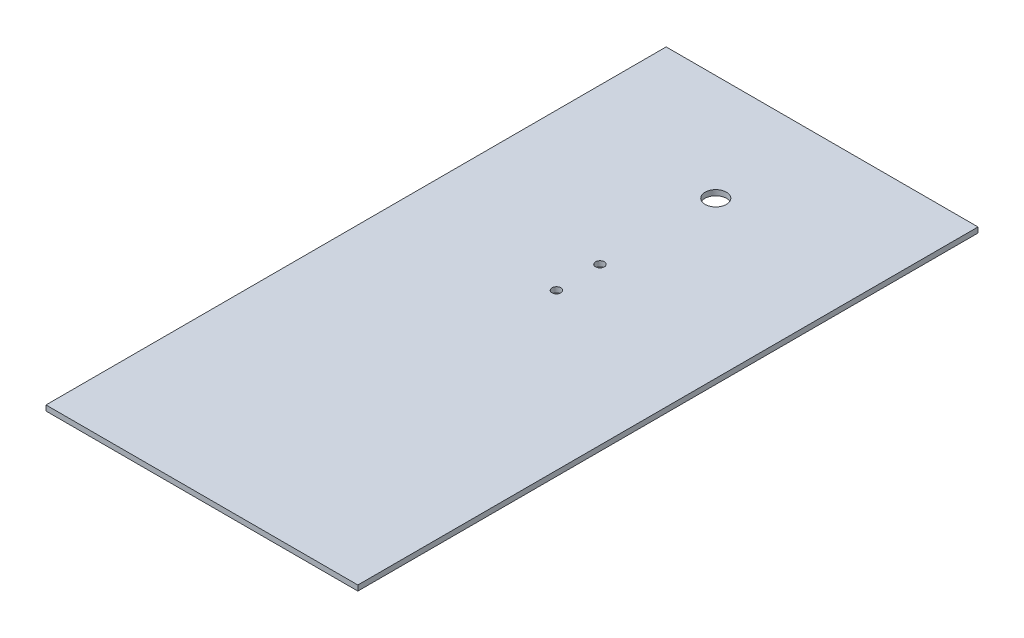
from build123d import *

# Parameters (mm, degrees)
SKETCH1_W                  = 176
SKETCH1_H                  = 350
BOSS_EXTRUDE1_DEPTH        = 3
F_5_0MM_DOWEL_HOLE1_D      = 5
F_5_0MM_DOWEL_HOLE1_DEPTH  = 3
F_12_0MM_DOWEL_HOLE1_D     = 12
F_12_0MM_DOWEL_HOLE1_DEPTH = 3
CUT_EXTRUDE3_DEPTH         = 0.5


with BuildPart() as part:
    # Sketch1 → Boss-Extrude1 (new body)
    with BuildSketch(Plane(origin=(0, 0, 0), x_dir=(1, 0, 0), z_dir=(0, 1, 0))):
        with Locations((88, 175)):
            Rectangle(SKETCH1_W, SKETCH1_H)
    extrude(amount=BOSS_EXTRUDE1_DEPTH)

    # Ø5.0mm Dowel Hole1
    with Locations(Plane(origin=(0, 0, 0), x_dir=(-1, 0, 0), z_dir=(0, -1, 0))):
        with Locations((-88.016913139, 200.06), (-87.591567674, 225.06)):
            Hole(F_5_0MM_DOWEL_HOLE1_D / 2, depth=F_5_0MM_DOWEL_HOLE1_DEPTH)

    # Ø12.0mm Dowel Hole1
    with Locations(Plane(origin=(0, 0, 0), x_dir=(-1, 0, 0), z_dir=(0, -1, 0))):
        with Locations((-88, 290)):
            Hole(F_12_0MM_DOWEL_HOLE1_D / 2, depth=F_12_0MM_DOWEL_HOLE1_DEPTH)

    # Sketch12 → Cut-Extrude3 (cut)
    with BuildSketch(Plane.XZ):
        with BuildLine():
            add(Edge.make_bspline(
                [(77.92675625, -206.794097), (77.93939, -206.794097), (78.28449275, -207.1306105), (78.693651, -207.54190525)],
                knots=[0, 0, 0, 0, 1, 1, 1, 1], degree=3))
            Line((78.693651, -207.54190525), (79.43757325, -208.2897145))
            Line((79.43757325, -208.2897145), (79.176767, -208.56564825))
            add(Edge.make_bspline(
                [(79.176767, -208.56564825), (79.03332975, -208.71741125), (78.538936, -209.15859025), (78.07812425, -209.546044)],
                knots=[0, 0, 0, 0, 1, 1, 1, 1], degree=3))
            add(Edge.make_bspline(
                [(78.07812425, -209.546044), (74.3622895, -212.67031475), (69.4527275, -214.46641025), (64.62846725, -214.46641025)],
                knots=[0, 0, 0, 0, 1, 1, 1, 1], degree=3))
            add(Edge.make_bspline(
                [(64.62846725, -214.46641025), (59.80542375, -214.46641025), (54.906584, -212.67482525), (51.1788165, -209.5476475)],
                knots=[0, 0, 0, 0, 1, 1, 1, 1], degree=3))
            add(Edge.make_bspline(
                [(51.1788165, -209.5476475), (50.7179985, -209.16107525), (50.26398675, -208.75889), (50.16990075, -208.653904)],
                knots=[0, 0, 0, 0, 1, 1, 1, 1], degree=3))
            Line((50.16990075, -208.653904), (49.99882125, -208.46301975))
            Line((49.99882125, -208.46301975), (50.7412155, -207.7167525))
            add(Edge.make_bspline(
                [(50.7412155, -207.7167525), (51.14952725, -207.30630575), (51.50432675, -206.971895), (51.5296475, -206.97361675)],
                knots=[0, 0, 0, 0, 1, 1, 1, 1], degree=3))
            add(Edge.make_bspline(
                [(51.5296475, -206.97361675), (51.55497475, -206.9753365), (51.98616625, -207.33088025), (52.48784925, -207.7637075)],
                knots=[0, 0, 0, 0, 1, 1, 1, 1], degree=3))
            add(Edge.make_bspline(
                [(52.48784925, -207.7637075), (56.826824, -211.5071315), (62.6097625, -213.01960175), (68.288541, -211.896223)],
                knots=[0, 0, 0, 0, 1, 1, 1, 1], degree=3))
            add(Edge.make_bspline(
                [(68.288541, -211.896223), (71.51028625, -211.258895), (74.32246975, -209.8757075), (76.89239425, -207.66437025)],
                knots=[0, 0, 0, 0, 1, 1, 1, 1], degree=3))
            add(Edge.make_bspline(
                [(76.89239425, -207.66437025), (77.44866075, -207.18572), (77.91412225, -206.794097), (77.92675625, -206.794097)],
                knots=[0, 0, 0, 0, 1, 1, 1, 1], degree=3))
        make_face()
        with BuildLine():
            add(Edge.make_bspline(
                [(69.71502225, -198.5920135), (69.732842, -198.5920135), (70.09417675, -198.94038175), (70.51798625, -199.3661645)],
                knots=[0, 0, 0, 0, 1, 1, 1, 1], degree=3))
            Line((70.51798625, -199.3661645), (71.28855225, -200.140315))
            Line((71.28855225, -200.140315), (70.78073075, -200.56986))
            add(Edge.make_bspline(
                [(70.78073075, -200.56986), (69.70705175, -201.47804225), (68.385028, -202.16285), (66.98377475, -202.53668575)],
                knots=[0, 0, 0, 0, 1, 1, 1, 1], degree=3))
            add(Edge.make_bspline(
                [(66.98377475, -202.53668575), (66.232186, -202.73719825), (65.95565025, -202.76505375), (64.716666, -202.76505375)],
                knots=[0, 0, 0, 0, 1, 1, 1, 1], degree=3))
            add(Edge.make_bspline(
                [(64.716666, -202.76505375), (63.47767525, -202.76505375), (63.20113925, -202.73719825), (62.44955075, -202.53668575)],
                knots=[0, 0, 0, 0, 1, 1, 1, 1], degree=3))
            add(Edge.make_bspline(
                [(62.44955075, -202.53668575), (61.44513275, -202.268721), (60.3126235, -201.7572305), (59.48578075, -201.1981145)],
                knots=[0, 0, 0, 0, 1, 1, 1, 1], degree=3))
            add(Edge.make_bspline(
                [(59.48578075, -201.1981145), (58.8494645, -200.7678345), (58.3225665, -200.31450075), (58.3225665, -200.19730275)],
                knots=[0, 0, 0, 0, 1, 1, 1, 1], degree=3))
            add(Edge.make_bspline(
                [(58.3225665, -200.19730275), (58.3225665, -200.15721125), (58.6572975, -199.7968825), (59.06641625, -199.3965705)],
                knots=[0, 0, 0, 0, 1, 1, 1, 1], degree=3))
            Line((59.06641625, -199.3965705), (59.81027225, -198.66873075))
            Line((59.81027225, -198.66873075), (60.2790875, -199.050287))
            add(Edge.make_bspline(
                [(60.2790875, -199.050287), (62.87973, -201.1668565), (66.80790625, -201.12243425), (69.27759975, -198.94852575)],
                knots=[0, 0, 0, 0, 1, 1, 1, 1], degree=3))
            add(Edge.make_bspline(
                [(69.27759975, -198.94852575), (69.50035925, -198.752445), (69.6972025, -198.5920135), (69.71502225, -198.5920135)],
                knots=[0, 0, 0, 0, 1, 1, 1, 1], degree=3))
        make_face()
        with BuildLine():
            add(Edge.make_bspline(
                [(61.05659225, -193.9632405), (61.05659225, -192.84240475), (61.7417505, -191.58765675), (62.6707025, -191.0072945)],
                knots=[0, 0, 0, 0, 1, 1, 1, 1], degree=3))
            Line((62.6707025, -191.0072945), (63.1647855, -190.69861375))
            Line((63.1647855, -190.69861375), (63.16901875, -187.1666285))
            Line((63.16901875, -187.1666285), (63.17325225, -183.63464275))
            Line((63.17325225, -183.63464275), (50.91627725, -165.9779275))
            Line((50.91627725, -165.9779275), (38.6592955, -148.32120725))
            Line((38.6592955, -148.32120725), (50.982423, -130.55459525))
            Line((50.982423, -130.55459525), (63.305544, -112.78798975))
            Line((63.305544, -112.78798975), (87.9999935, -112.78798975))
            Line((87.9999935, -112.78798975), (112.69443425, -112.78798975))
            Line((112.69443425, -112.78798975), (125.01748575, -130.55448275))
            Line((125.01748575, -130.55448275), (137.3405285, -148.321161))
            Line((137.3405285, -148.321161), (125.01748575, -166.0877175))
            Line((125.01748575, -166.0877175), (112.6944435, -183.85427075))
            Line((112.6944435, -183.85427075), (89.344963, -183.8589075))
            Line((89.344963, -183.8589075), (65.99548325, -183.8635445))
            Line((65.99548325, -183.8635445), (65.99548325, -187.242146))
            Line((65.99548325, -187.242146), (65.99548325, -190.62074675))
            Line((65.99548325, -190.62074675), (66.538428, -190.968361))
            add(Edge.make_bspline(
                [(66.538428, -190.968361), (67.52104425, -191.597474), (68.20034225, -192.821029), (68.20034225, -193.96180775)],
                knots=[0, 0, 0, 0, 1, 1, 1, 1], degree=3))
            add(Edge.make_bspline(
                [(68.20034225, -193.96180775), (68.20034225, -196.2879175), (65.8544735, -198.043799), (63.64384675, -197.372342)],
                knots=[0, 0, 0, 0, 1, 1, 1, 1], degree=3))
            add(Edge.make_bspline(
                [(63.64384675, -197.372342), (62.1379045, -196.914923), (61.05659225, -195.490141), (61.05659225, -193.9632405)],
                knots=[0, 0, 0, 0, 1, 1, 1, 1], degree=3))
        make_face()
        with BuildLine():
            add(Edge.make_bspline(
                [(126.55098425, -148.27426375), (126.5225145, -148.19764025), (111.242934, -126.15327125), (108.84036725, -122.7225515)],
                knots=[0, 0, 0, 0, 1, 1, 1, 1], degree=3))
            Line((108.84036725, -122.7225515), (108.05274975, -121.59788725))
            Line((108.05274975, -121.59788725), (87.98007025, -121.62011875))
            Line((87.98007025, -121.62011875), (67.907389, -121.64236375))
            Line((67.907389, -121.64236375), (58.661703, -134.9597225))
            add(Edge.make_bspline(
                [(58.661703, -134.9597225), (53.57657, -142.284269), (49.41605, -148.29692525), (49.416103, -148.321181)],
                knots=[0, 0, 0, 0, 1, 1, 1, 1], degree=3))
            add(Edge.make_bspline(
                [(49.416103, -148.321181), (49.4161425, -148.3454365), (53.576742, -154.35809075), (58.66186175, -161.68263925)],
                knots=[0, 0, 0, 0, 1, 1, 1, 1], degree=3))
            Line((58.66186175, -161.68263925), (67.9075345, -175))
            Line((67.9075345, -175), (88, -175))
            Line((88, -175), (108.092461, -175))
            Line((108.092461, -175), (117.33863125, -161.68263925))
            add(Edge.make_bspline(
                [(117.33863125, -161.68263925), (122.42402525, -154.35809075), (126.56958375, -148.32432275), (126.55098425, -148.27426375)],
                knots=[0, 0, 0, 0, 1, 1, 1, 1], degree=3))
        make_face(mode=Mode.SUBTRACT)
        with BuildLine():
            add(Edge.make_bspline(
                [(103.213541, -139.98986175), (103.77137075, -139.97187675), (104.3468395, -139.9760175), (104.49236025, -139.999056)],
                knots=[0, 0, 0, 0, 1, 1, 1, 1], degree=3))
            add(Edge.make_bspline(
                [(104.49236025, -139.999056), (106.4280235, -140.305576), (107.922166, -141.03417225), (109.24030675, -142.31432575)],
                knots=[0, 0, 0, 0, 1, 1, 1, 1], degree=3))
            add(Edge.make_bspline(
                [(109.24030675, -142.31432575), (110.37634425, -143.417625), (111.142309, -144.7439945), (111.52243525, -146.266129)],
                knots=[0, 0, 0, 0, 1, 1, 1, 1], degree=3))
            add(Edge.make_bspline(
                [(111.52243525, -146.266129), (111.7959385, -147.36131875), (111.7959385, -149.1046585), (111.52243525, -150.1998415)],
                knots=[0, 0, 0, 0, 1, 1, 1, 1], degree=3))
            add(Edge.make_bspline(
                [(111.52243525, -150.1998415), (111.156707, -151.6643235), (110.47042875, -152.88966325), (109.39678275, -153.99516975)],
                knots=[0, 0, 0, 0, 1, 1, 1, 1], degree=3))
            add(Edge.make_bspline(
                [(109.39678275, -153.99516975), (108.29348425, -155.13120725), (106.96711475, -155.897172), (105.44497925, -156.27729825)],
                knots=[0, 0, 0, 0, 1, 1, 1, 1], degree=3))
            add(Edge.make_bspline(
                [(105.44497925, -156.27729825), (104.837269, -156.42906325), (104.41026325, -156.471148), (103.47812425, -156.471148)],
                knots=[0, 0, 0, 0, 1, 1, 1, 1], degree=3))
            add(Edge.make_bspline(
                [(103.47812425, -156.471148), (102.54598475, -156.471148), (102.118979, -156.42906325), (101.51126875, -156.27729825)],
                knots=[0, 0, 0, 0, 1, 1, 1, 1], degree=3))
            add(Edge.make_bspline(
                [(101.51126875, -156.27729825), (99.9726365, -155.8930525), (98.6337205, -155.11483025), (97.5378925, -153.96783975)],
                knots=[0, 0, 0, 0, 1, 1, 1, 1], degree=3))
            add(Edge.make_bspline(
                [(97.5378925, -153.96783975), (96.455115, -152.83451075), (95.797814, -151.65741125), (95.43381275, -150.1998415)],
                knots=[0, 0, 0, 0, 1, 1, 1, 1], degree=3))
            add(Edge.make_bspline(
                [(95.43381275, -150.1998415), (95.1603095, -149.1046585), (95.1603095, -147.36131875), (95.43381275, -146.266129)],
                knots=[0, 0, 0, 0, 1, 1, 1, 1], degree=3))
            add(Edge.make_bspline(
                [(95.43381275, -146.266129), (95.813939, -144.7439945), (96.57990375, -143.417625), (97.71594125, -142.31432575)],
                knots=[0, 0, 0, 0, 1, 1, 1, 1], degree=3))
            add(Edge.make_bspline(
                [(97.71594125, -142.31432575), (99.26936675, -140.80566475), (101.0325205, -140.0601815), (103.213541, -139.98986175)],
                knots=[0, 0, 0, 0, 1, 1, 1, 1], degree=3))
        make_face()
        with BuildLine():
            add(Edge.make_bspline(
                [(72.34548325, -139.98986175), (72.903311, -139.97187675), (73.47877975, -139.9760175), (73.6243005, -139.999056)],
                knots=[0, 0, 0, 0, 1, 1, 1, 1], degree=3))
            add(Edge.make_bspline(
                [(73.6243005, -139.999056), (75.55996575, -140.305576), (77.0541075, -141.03417225), (78.3722485, -142.31432575)],
                knots=[0, 0, 0, 0, 1, 1, 1, 1], degree=3))
            add(Edge.make_bspline(
                [(78.3722485, -142.31432575), (79.50828325, -143.417625), (80.274252, -144.7439945), (80.654379, -146.266129)],
                knots=[0, 0, 0, 0, 1, 1, 1, 1], degree=3))
            add(Edge.make_bspline(
                [(80.654379, -146.266129), (80.92787875, -147.36131875), (80.92787875, -149.1046585), (80.654379, -150.1998415)],
                knots=[0, 0, 0, 0, 1, 1, 1, 1], degree=3))
            add(Edge.make_bspline(
                [(80.654379, -150.1998415), (80.288652, -151.6643235), (79.602369, -152.88966325), (78.528723, -153.99516975)],
                knots=[0, 0, 0, 0, 1, 1, 1, 1], degree=3))
            add(Edge.make_bspline(
                [(78.528723, -153.99516975), (77.42542375, -155.13120725), (76.09905425, -155.897172), (74.5769195, -156.27729825)],
                knots=[0, 0, 0, 0, 1, 1, 1, 1], degree=3))
            add(Edge.make_bspline(
                [(74.5769195, -156.27729825), (73.96921125, -156.42906325), (73.542207, -156.471148), (72.6100665, -156.471148)],
                knots=[0, 0, 0, 0, 1, 1, 1, 1], degree=3))
            add(Edge.make_bspline(
                [(72.6100665, -156.471148), (71.67792625, -156.471148), (71.25092175, -156.42906325), (70.6432135, -156.27729825)],
                knots=[0, 0, 0, 0, 1, 1, 1, 1], degree=3))
            add(Edge.make_bspline(
                [(70.6432135, -156.27729825), (69.1045755, -155.8930525), (67.76566475, -155.11483025), (66.6698335, -153.96783975)],
                knots=[0, 0, 0, 0, 1, 1, 1, 1], degree=3))
            add(Edge.make_bspline(
                [(66.6698335, -153.96783975), (65.58705925, -152.83451075), (64.92975475, -151.65741125), (64.56575425, -150.1998415)],
                knots=[0, 0, 0, 0, 1, 1, 1, 1], degree=3))
            add(Edge.make_bspline(
                [(64.56575425, -150.1998415), (64.292248, -149.1046585), (64.292248, -147.36131875), (64.56575425, -146.266129)],
                knots=[0, 0, 0, 0, 1, 1, 1, 1], degree=3))
            add(Edge.make_bspline(
                [(64.56575425, -146.266129), (64.94588125, -144.7439945), (65.71184325, -143.417625), (66.84788475, -142.31432575)],
                knots=[0, 0, 0, 0, 1, 1, 1, 1], degree=3))
            add(Edge.make_bspline(
                [(66.84788475, -142.31432575), (68.4013065, -140.80566475), (70.16446325, -140.0601815), (72.34548325, -139.98986175)],
                knots=[0, 0, 0, 0, 1, 1, 1, 1], degree=3))
        make_face()
        with BuildLine():
            add(Edge.make_bspline(
                [(60.5274255, -206.03509275), (61.96572025, -206.510037), (62.91536275, -206.6511815), (64.6725665, -206.6511815)],
                knots=[0, 0, 0, 0, 1, 1, 1, 1], degree=3))
            add(Edge.make_bspline(
                [(64.6725665, -206.6511815), (66.03292175, -206.6511815), (66.45811375, -206.61812725), (67.23020775, -206.4523485)],
                knots=[0, 0, 0, 0, 1, 1, 1, 1], degree=3))
            add(Edge.make_bspline(
                [(67.23020775, -206.4523485), (69.5899405, -205.945684), (71.501039, -204.999856), (73.280243, -203.4581105)],
                knots=[0, 0, 0, 0, 1, 1, 1, 1], degree=3))
            Line((73.280243, -203.4581105), (73.994512, -202.839166))
            Line((73.994512, -202.839166), (74.76425775, -203.612491))
            Line((74.76425775, -203.612491), (75.53399675, -204.385817))
            Line((75.53399675, -204.385817), (74.97602375, -204.89206025))
            add(Edge.make_bspline(
                [(74.97602375, -204.89206025), (72.5058405, -207.1332325), (69.580184, -208.44532125), (66.21596725, -208.82073975)],
                knots=[0, 0, 0, 0, 1, 1, 1, 1], degree=3))
            add(Edge.make_bspline(
                [(66.21596725, -208.82073975), (62.26491125, -209.26164675), (58.1263185, -208.00259925), (54.93635625, -205.389242)],
                knots=[0, 0, 0, 0, 1, 1, 1, 1], degree=3))
            add(Edge.make_bspline(
                [(54.93635625, -205.389242), (54.5917035, -205.10688675), (54.23245875, -204.78970275), (54.138029, -204.684388)],
                knots=[0, 0, 0, 0, 1, 1, 1, 1], degree=3))
            Line((54.138029, -204.684388), (53.96633425, -204.49290525))
            Line((53.96633425, -204.49290525), (54.72896275, -203.7302835))
            Line((54.72896275, -203.7302835), (55.49157775, -202.967661))
            Line((55.49157775, -202.967661), (56.010611, -203.41909775))
            add(Edge.make_bspline(
                [(56.010611, -203.41909775), (57.31365075, -204.55244825), (59.0063755, -205.53282025), (60.5274255, -206.03509275)],
                knots=[0, 0, 0, 0, 1, 1, 1, 1], degree=3))
        make_face()
    extrude(amount=-CUT_EXTRUDE3_DEPTH, mode=Mode.SUBTRACT)


solid = part.part
